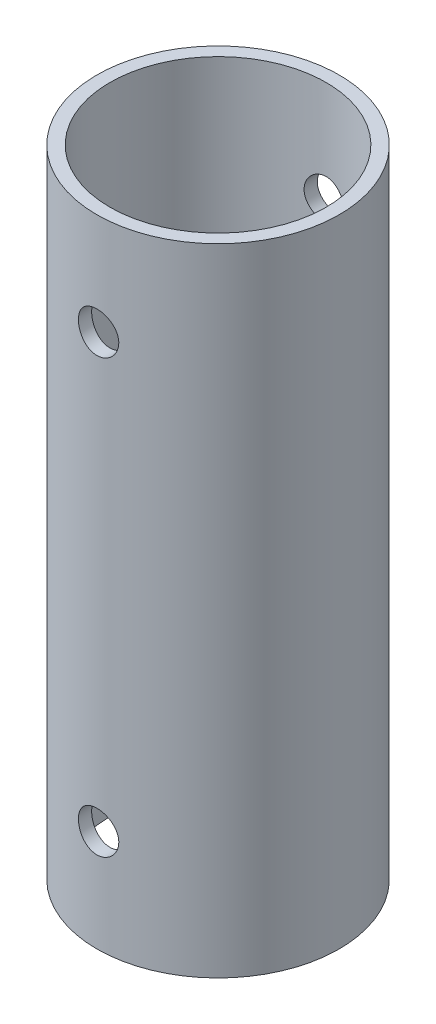
from build123d import *

# Parameters (mm, degrees)
CROQUIS2_R                 = 9.525
CROQUIS2_R_2               = 8.5
SALIENTE_EXTRUIR1_DEPTH    = 50
CROQUIS3_R                 = 1.5875
CORTAR_EXTRUIR1_DEPTH      = 10.525
CORTAR_EXTRUIR1_DEPTH_BACK = 10.525


with BuildPart() as part:
    # Croquis2 → Saliente-Extruir1 (new body)
    with BuildSketch(Plane(origin=(0, 0, 0), x_dir=(1, 0, 0), z_dir=(0, 1, 0))):
        Circle(CROQUIS2_R)
        Circle(CROQUIS2_R_2, mode=Mode.SUBTRACT)
    extrude(amount=SALIENTE_EXTRUIR1_DEPTH)

    # Croquis3 → Cortar-Extruir1 (cut, two sides)
    with BuildSketch(Plane.XY) as cortar_extruir1_sk:
        with Locations((0, 42.0025)):
            Circle(CROQUIS3_R)
        with Locations((0, 8)):
            Circle(CROQUIS3_R)
    extrude(amount=CORTAR_EXTRUIR1_DEPTH, mode=Mode.SUBTRACT)
    extrude(cortar_extruir1_sk.sketch, amount=-CORTAR_EXTRUIR1_DEPTH_BACK, mode=Mode.SUBTRACT)


solid = part.part
